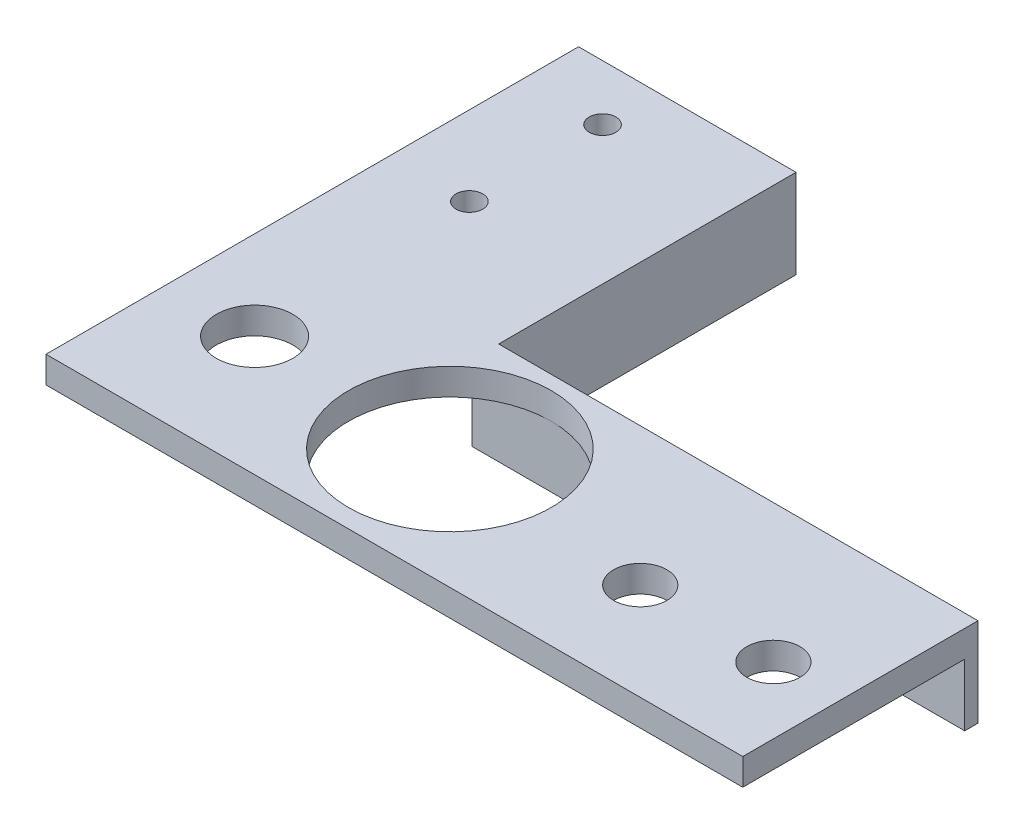
from build123d import *

# Parameters (mm, degrees)
SALIENTE_EXTRUIR1_DEPTH = 3
CROQUIS2_R              = 3
CROQUIS2_R_2            = 1.5
CORTAR_EXTRUIR2_DEPTH   = 4
SALIENTE_EXTRUIR2_DEPTH = 10
CROQUIS4_R              = 11.420621249
CORTAR_EXTRUIR3_DEPTH   = 11
CROQUIS5_W              = 78.5
CROQUIS5_H              = 3
SALIENTE_EXTRUIR3_DEPTH = 2
CROQUIS6_R              = 4.304654485
CORTAR_EXTRUIR4_DEPTH   = 11


with BuildPart() as part:
    # Croquis1 → Saliente-Extruir1 (new body)
    with BuildSketch(Plane(origin=(0, 0, 0), x_dir=(1, 0, 0), z_dir=(0, 1, 0))):
        Polygon((-16.25, 29), (-16.25, -6), (39.25, -6), (39.25, -29), (-39.25, -29), (-39.25, 29), align=None)
    extrude(amount=SALIENTE_EXTRUIR1_DEPTH)

    # Croquis2 → Cortar-Extruir2 (cut, through all)
    with BuildSketch(Plane(origin=(0, 3, 0), x_dir=(1, 0, 0), z_dir=(0, 1, 0))):
        with Locations((31.75, -20.05)):
            Circle(CROQUIS2_R)
        with Locations((16.75, -20.05)):
            Circle(CROQUIS2_R)
        with Locations((-30.3, 22.75)):
            Circle(CROQUIS2_R_2)
        with Locations((-30.3, 7.75)):
            Circle(CROQUIS2_R_2)
    extrude(amount=-CORTAR_EXTRUIR2_DEPTH, mode=Mode.SUBTRACT)

    # Croquis3 → Saliente-Extruir2 (add)
    with BuildSketch(Plane(origin=(0, 3, 0), x_dir=(1, 0, 0), z_dir=(0, 1, 0))):
        Polygon((-16.25, 29), (-16.25, -6), (39.25, -6), (39.25, -4.5), (-14.75, -4.5), (-14.75, 29), align=None)
    extrude(amount=-SALIENTE_EXTRUIR2_DEPTH)

    # Croquis4 → Cortar-Extruir3 (cut, through all)
    with BuildSketch(Plane(origin=(0, 3, 0), x_dir=(1, 0, 0), z_dir=(0, 1, 0))):
        with Locations((-7.25, -17.5)):
            Circle(CROQUIS4_R)
    extrude(amount=-CORTAR_EXTRUIR3_DEPTH, mode=Mode.SUBTRACT)

    # Croquis5 → Saliente-Extruir3 (add)
    with BuildSketch(Plane.XY.offset(29)):
        with Locations((0, 1.5)):
            Rectangle(CROQUIS5_W, CROQUIS5_H)
    extrude(amount=SALIENTE_EXTRUIR3_DEPTH)

    # Croquis6 → Cortar-Extruir4 (cut, through all)
    with BuildSketch(Plane(origin=(0, 3, 0), x_dir=(1, 0, 0), z_dir=(0, 1, 0))):
        with Locations((-29.25, -17.5)):
            Circle(CROQUIS6_R)
    extrude(amount=-CORTAR_EXTRUIR4_DEPTH, mode=Mode.SUBTRACT)


solid = part.part
